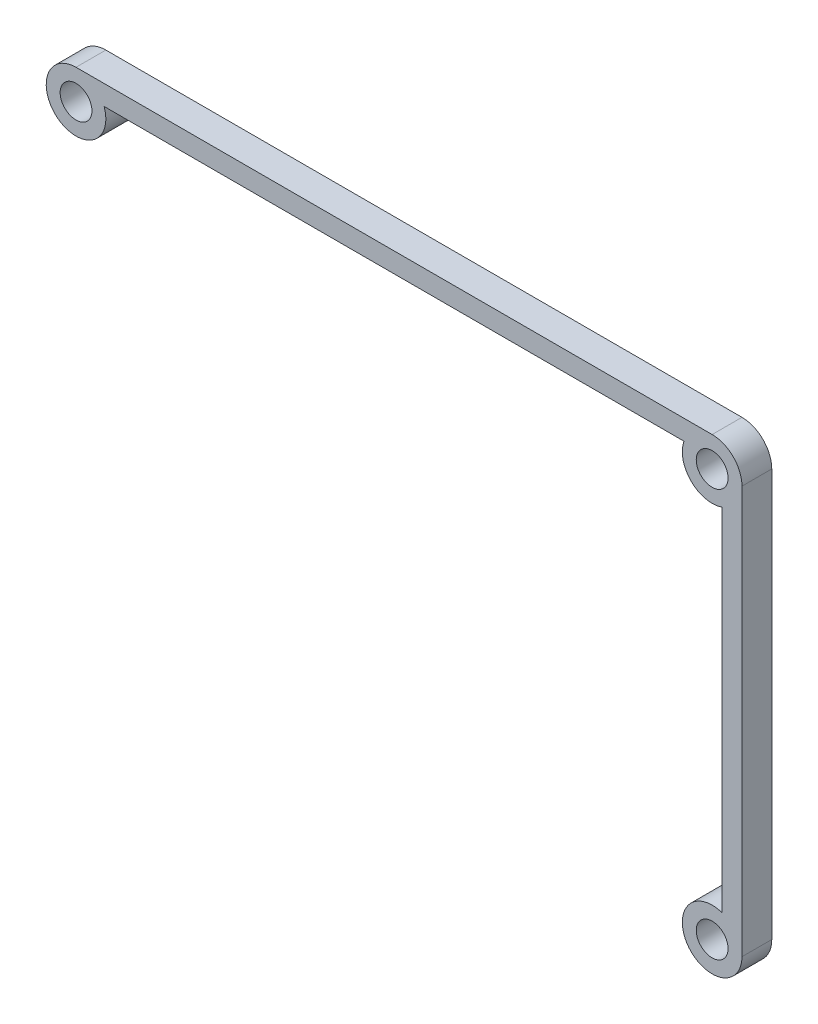
from build123d import *

# Parameters (mm, degrees)
ESBO_O1_R                = 1.6
RESSALTO_EXTRUS_O1_DEPTH = 3


with BuildPart() as part:
    # Esboço1 → Ressalto-extrusão1 (new body)
    with BuildSketch(Plane.XY):
        with BuildLine():
            Line((35, 20.5), (35, -20.5))
            ThreePointArc((35, -20.5), (29.550510257, -22.232050808), (33, -17.671572875))
            Line((33, -17.671572875), (33, 17.671572875))
            ThreePointArc((33, 17.671572875), (29.878679656, 18.378679656), (29.171572875, 21.5))
            Line((29.171572875, 21.5), (-29.171572875, 21.5))
            ThreePointArc((-29.171572875, 21.5), (-33.732050808, 18.050510257), (-32, 23.5))
            Line((-32, 23.5), (32, 23.5))
            ThreePointArc((32, 23.5), (34.121320344, 22.621320344), (35, 20.5))
        make_face()
        with Locations((-32, 20.5)):
            Circle(ESBO_O1_R, mode=Mode.SUBTRACT)
        with Locations((32, 20.5)):
            Circle(ESBO_O1_R, mode=Mode.SUBTRACT)
        with Locations((32, -20.5)):
            Circle(ESBO_O1_R, mode=Mode.SUBTRACT)
    extrude(amount=RESSALTO_EXTRUS_O1_DEPTH)


solid = part.part
